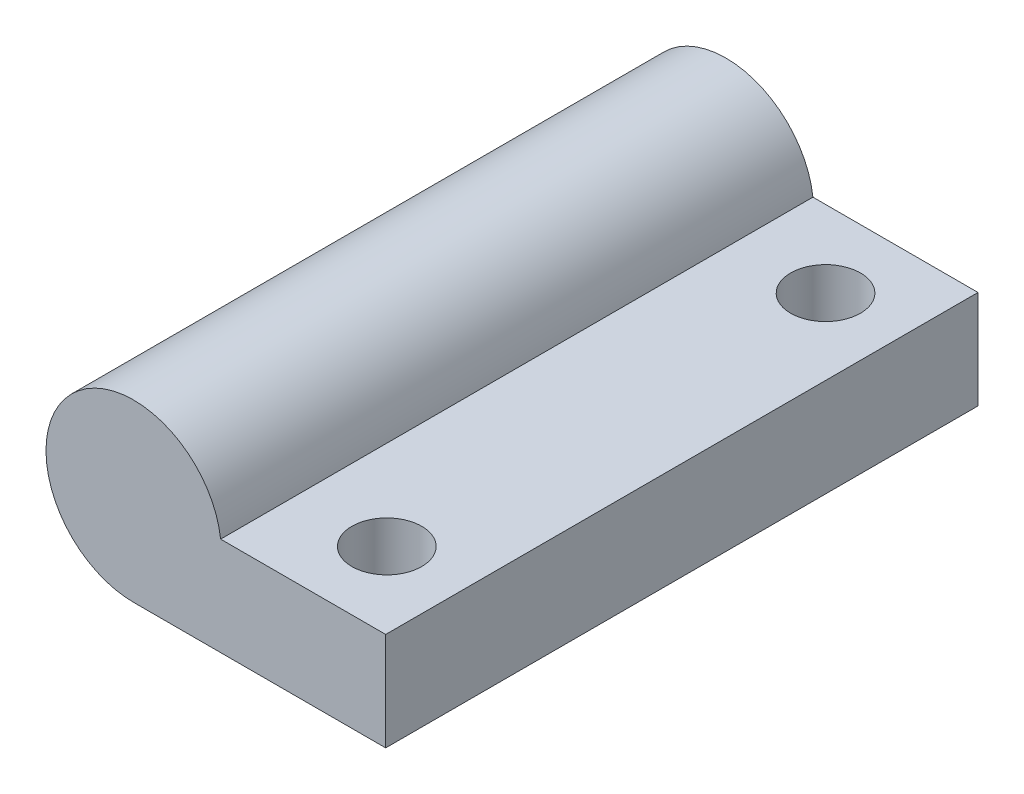
from build123d import *

# Parameters (mm, degrees)
BOSS_EXTRUDE1_DEPTH            = 42.8625
F_8_0_199_DIAMETER_HOLE1_D     = 5.0546
F_8_0_199_DIAMETER_HOLE1_DEPTH = 6.35
F_8_0_199_DIAMETER_HOLE1_TIP   = 1.518555042


with BuildPart() as part:
    # Sketch1 → Boss-Extrude1 (new body)
    with BuildSketch(Plane.XY):
        with BuildLine():
            Line((-19.0864, 25.721816942), (-0.91057904, 25.721816942))
            Line((-0.91057904, 25.721816942), (-0.91057904, 32.833816942))
            Line((-0.91057904, 32.833816942), (-12.854560562, 32.833816942))
            ThreePointArc((-12.854560562, 32.833816942), (-23.919686684, 36.243252538), (-19.0864, 25.721816942))
        make_face()
    extrude(amount=BOSS_EXTRUDE1_DEPTH)

    # #8 (0.199) Diameter Hole1
    with Locations(Plane(origin=(0, 32.833816942, 0), x_dir=(-1, 0, 0), z_dir=(0, 1, 0))):
        with Locations((6.3864, 37.30625), (6.3864, 5.55625)):
            Hole(F_8_0_199_DIAMETER_HOLE1_D / 2, depth=F_8_0_199_DIAMETER_HOLE1_DEPTH)
            with Locations((0, 0, -(F_8_0_199_DIAMETER_HOLE1_DEPTH + F_8_0_199_DIAMETER_HOLE1_TIP / 2))):  # 118° drill point
                Cone(0, F_8_0_199_DIAMETER_HOLE1_D / 2, F_8_0_199_DIAMETER_HOLE1_TIP, mode=Mode.SUBTRACT)


solid = part.part
